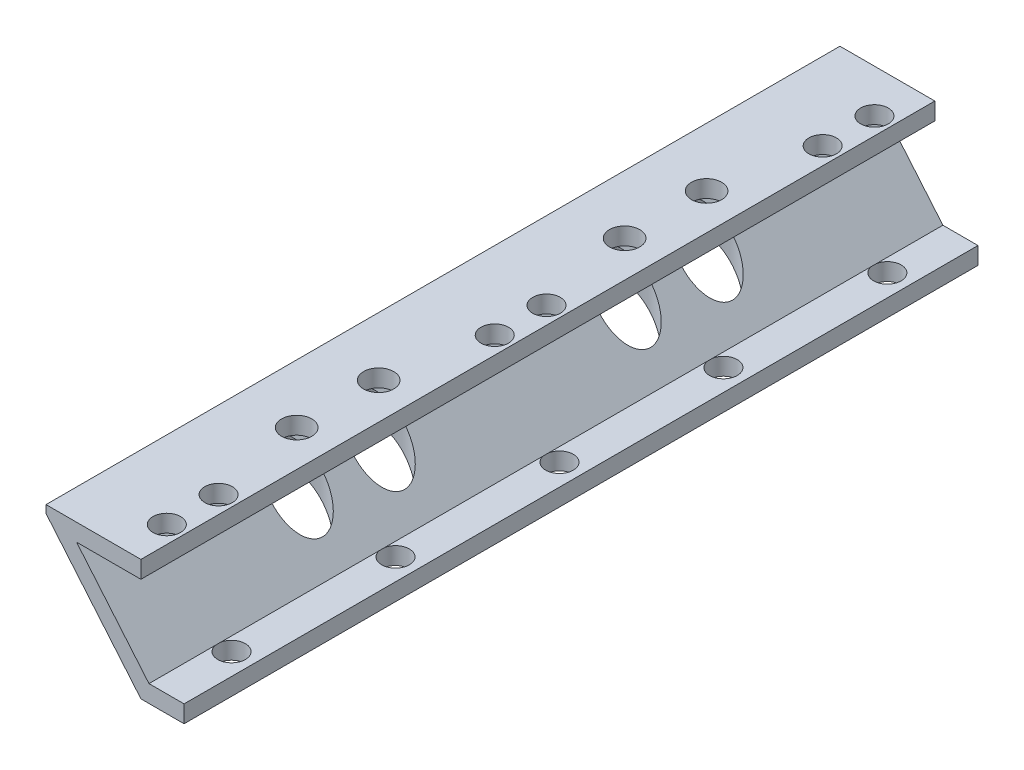
from build123d import *

# Parameters (mm, degrees)
EXTRUDE_1_DEPTH      = 46
EXTRUDE_1_DEPTH_BACK = 46
SKETCH_2_R           = 1.6
CUT_EXTRUDE_1_DEPTH  = 5
SKETCH_3_R           = 1.6
CUT_EXTRUDE_2_DEPTH  = 5
SKETCH_4_R           = 1.75
CUT_EXTRUDE_3_DEPTH  = 10
SKETCH_5_R           = 3
CUT_EXTRUDE_4_DEPTH  = 20
SKETCH_6_W           = 108.593038012
SKETCH_6_H           = 21.321920706
CUT_EXTRUDE_5_DEPTH  = 20


with BuildPart() as part:
    # 스케치1 → 보스-돌출1 (new, two sides: drawn at the far end of the back side and taken through both)
    with BuildSketch(Plane.XY.offset(-EXTRUDE_1_DEPTH_BACK)):
        Polygon((5, 0), (0, 0), (-10.069195574, 12), (-11, 12), (-11, 14), (0, 14), (0, 12), (-7.458380995, 12), (0.932615316, 2), (5, 2), align=None)
    extrude(amount=EXTRUDE_1_DEPTH + EXTRUDE_1_DEPTH_BACK)

    # 스케치2 → 컷-돌출1 (cut)
    with BuildSketch(Plane(origin=(0, 14, 0), x_dir=(1, 0, 0), z_dir=(0, 1, 0))):
        with Locations((-2, 41)):
            Circle(SKETCH_2_R)
        with Locations((-2, 35)):
            Circle(SKETCH_2_R)
        with Locations((-2, 3)):
            Circle(SKETCH_2_R)
        with Locations((-2, -3)):
            Circle(SKETCH_2_R)
        with Locations((-2, -35)):
            Circle(SKETCH_2_R)
        with Locations((-2, -41)):
            Circle(SKETCH_2_R)
    extrude(amount=-CUT_EXTRUDE_1_DEPTH, mode=Mode.SUBTRACT)

    # 스케치3 → 컷-돌출2 (cut)
    with BuildSketch(Plane(origin=(0, 2, 0), x_dir=(1.0, 1.17531647254689e-12, 0), z_dir=(-1.17531647254689e-12, 1.0, 0))):
        with Locations((2.5, 38)):
            Circle(SKETCH_3_R)
        with Locations((2.5, 19)):
            Circle(SKETCH_3_R)
        with Locations((2.5, 0)):
            Circle(SKETCH_3_R)
        with Locations((2.5, -19)):
            Circle(SKETCH_3_R)
        with Locations((2.5, -38)):
            Circle(SKETCH_3_R)
    extrude(amount=-CUT_EXTRUDE_2_DEPTH, mode=Mode.SUBTRACT)

    # 스케치4 → 컷-돌출3 (cut)
    with BuildSketch(Plane(origin=(0, 14, 0), x_dir=(1, 0, 0), z_dir=(0, 1, 0))):
        with Locations((-4.2, 23.75)):
            Circle(SKETCH_4_R)
        with Locations((-4.2, 14.25)):
            Circle(SKETCH_4_R)
        with Locations((-4.2, -14.25)):
            Circle(SKETCH_4_R)
        with Locations((-4.2, -23.75)):
            Circle(SKETCH_4_R)
    extrude(amount=-CUT_EXTRUDE_3_DEPTH, mode=Mode.SUBTRACT)

    # 스케치5 → 컷-돌출4 (cut)
    with BuildSketch(Plane.XZ.offset(-12)):
        with Locations((-4.2, 23.75)):
            Circle(SKETCH_5_R)
        with Locations((-4.2, 14.25)):
            Circle(SKETCH_5_R)
        with Locations((-4.2, -14.25)):
            Circle(SKETCH_5_R)
        with Locations((-4.2, -23.75)):
            Circle(SKETCH_5_R)
    extrude(amount=CUT_EXTRUDE_4_DEPTH, mode=Mode.SUBTRACT)

    # 스케치6 → 컷-돌출5 (cut)
    with BuildSketch(Plane(origin=(0, 0, 0), x_dir=(0, 0, 1), z_dir=(-0.766044443118979, -0.6427876096865381, 0))):
        with Locations((-2.330535519, 21.720159804)):
            Rectangle(SKETCH_6_W, SKETCH_6_H)
    extrude(amount=CUT_EXTRUDE_5_DEPTH, mode=Mode.SUBTRACT)


solid = part.part
